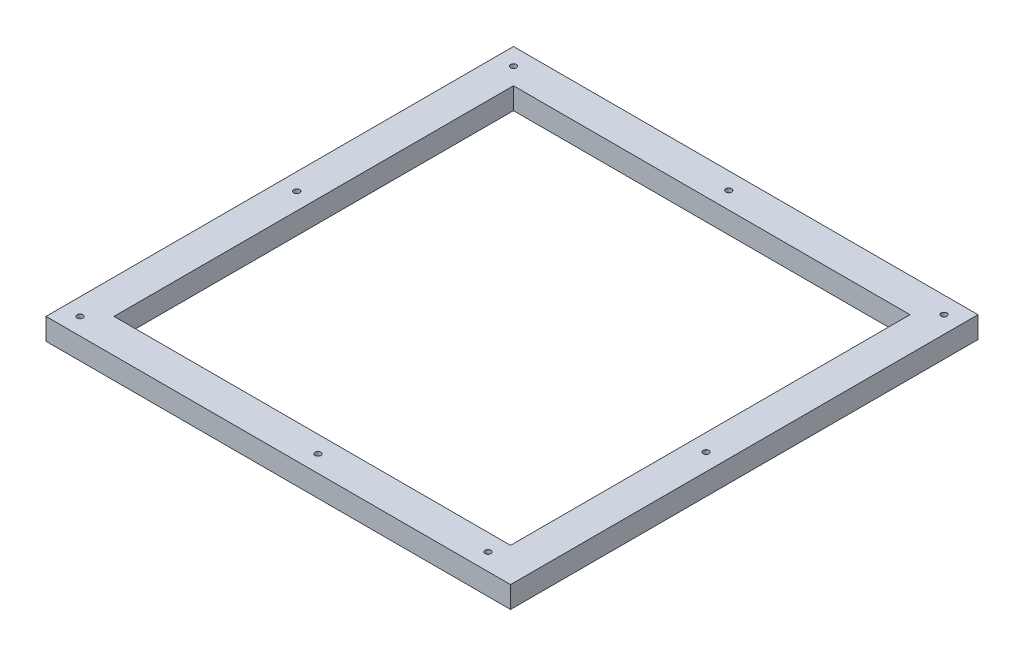
from build123d import *

# Parameters (mm, degrees)
SKETCH1_W                      = 273.27
SKETCH1_H                      = 275
BOSS_EXTRUDE1_DEPTH            = 12.7
SKETCH2_W                      = 233.27
SKETCH2_H                      = 235
CUT_EXTRUDE1_DEPTH             = 12.7
M3_CLEARANCE_HOLE1_D           = 3.4
M3_CLEARANCE_HOLE1_CSINK_D     = 3.45
M3_CLEARANCE_HOLE1_CSINK_ANGLE = 90
M3_CLEARANCE_HOLE2_D           = 3.4
M3_CLEARANCE_HOLE2_CSINK_D     = 3.45
M3_CLEARANCE_HOLE2_CSINK_ANGLE = 90


with BuildPart() as part:
    # Sketch1 → Boss-Extrude1 (new body)
    with BuildSketch(Plane(origin=(0, 0, 0), x_dir=(1, 0, 0), z_dir=(0, 1, 0))):
        Rectangle(SKETCH1_W, SKETCH1_H)
    extrude(amount=BOSS_EXTRUDE1_DEPTH)

    # Sketch2 → Cut-Extrude1 (cut)
    with BuildSketch(Plane(origin=(0, 12.7, 0), x_dir=(1, 0, 0), z_dir=(0, 1, 0))):
        Rectangle(SKETCH2_W, SKETCH2_H)
    extrude(amount=-CUT_EXTRUDE1_DEPTH, mode=Mode.SUBTRACT)

    # M3 Clearance Hole1 (through all)
    with Locations(Plane(origin=(0, 12.7, 0), x_dir=(1, 0, 0), z_dir=(0, 1, 0))):
        with Locations((0, 127.5), (-126.635, 127.5), (126.6328, 127.5), (-126.635, 0), (13.3689, -127.5), (113.3689, -127.5), (126.6328, -12.5)):
            CounterSinkHole(M3_CLEARANCE_HOLE1_D / 2, M3_CLEARANCE_HOLE1_CSINK_D / 2, counter_sink_angle=M3_CLEARANCE_HOLE1_CSINK_ANGLE)

    # M3 Clearance Hole2 (through all)
    with Locations(Plane(origin=(0, 12.7, 0), x_dir=(1, 0, 0), z_dir=(0, 1, 0))):
        with Locations((-126.6311, -127.5)):
            CounterSinkHole(M3_CLEARANCE_HOLE2_D / 2, M3_CLEARANCE_HOLE2_CSINK_D / 2, counter_sink_angle=M3_CLEARANCE_HOLE2_CSINK_ANGLE)


solid = part.part
